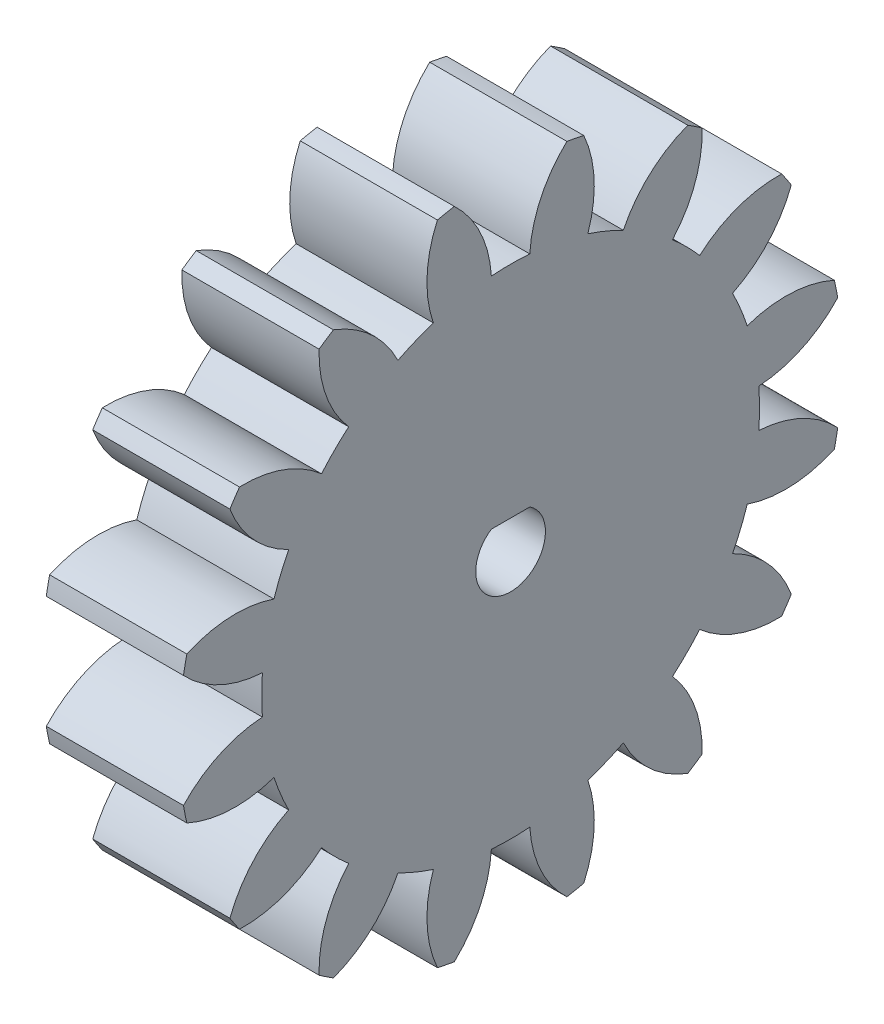
from build123d import *

# Parameters (mm, degrees)
BASPROSKE_W        = 11.811
BASPROSKE_H        = 28.575
TOOTHCUT_DEPTH     = 43.101792967
TEETHCUTS_COUNT    = 16
TEETHCUTS_ANGLE    = 337.5
BORSKE_R           = 0.396875
BORE_DEPTH         = 50.8000508
CUT_EXTRUDE1_DEPTH = 42.540449503


with BuildPart() as part:
    # BasProSke → Base-Revolve (revolve)
    with BuildSketch(Plane(origin=(0, 0, 0), x_dir=(1, 0, 0), z_dir=(0, 1, 0)), mode=Mode.PRIVATE) as base_revolve_sk:
        with Locations((5.9055, 14.2875)):
            Rectangle(BASPROSKE_W, BASPROSKE_H)
    revolve(base_revolve_sk.sketch.rotate(Axis((-10, 0, 0), (1, 0, 0)), 180), axis=Axis((-10, 0, 0), (1, 0, 0)))

    # TooCutSke → ToothCut (cut, through all)
    with BuildSketch(Plane(origin=(0, 0, 0), x_dir=(0, 0, -1), z_dir=(1, 0, 0))):
        with BuildLine():
            ThreePointArc((1.653773222, 21.366073035), (0, 21.42998), (-1.653773222, 21.366073035))
            ThreePointArc((-1.653773222, 21.366073035), (-2.605634946, 25.083646688), (-4.868483936, 28.182986789))
            ThreePointArc((-4.868483936, 28.182986789), (0, 28.6004), (4.868483936, 28.182986789))
            ThreePointArc((4.868483936, 28.182986789), (2.605634946, 25.083646688), (1.653773222, 21.366073035))
        make_face()
    toothcut = extrude(amount=TOOTHCUT_DEPTH, mode=Mode.SUBTRACT)

    # TeethCuts: ToothCut ×16 about axis
    teethcuts_axis = Axis((-10, 0, 0), (1, 0, 0))
    for i in range(1, TEETHCUTS_COUNT):
        add(toothcut.rotate(teethcuts_axis, i * TEETHCUTS_ANGLE / (TEETHCUTS_COUNT - 1)), mode=Mode.SUBTRACT)

    # BorSke → Bore (cut, symmetric)
    with BuildSketch(Plane(origin=(0, 0, 0), x_dir=(0, 0, -1), z_dir=(1, 0, 0))):
        with Locations(Location((0, 0, 0), (0, 0, 180))):
            Circle(BORSKE_R)
    extrude(amount=BORE_DEPTH, both=True, mode=Mode.SUBTRACT)

    # Sketch1 → Cut-Extrude1 (cut, through all)
    with BuildSketch(Plane(origin=(11.811, 0, 0), x_dir=(0, 0, -1), z_dir=(1, 0, 0))):
        with BuildLine():
            Line((-1.658312395, 2.5), (1.658312395, 2.5))
            ThreePointArc((1.658312395, 2.5), (0, -3), (-1.658312395, 2.5))
        make_face()
    extrude(amount=-CUT_EXTRUDE1_DEPTH, mode=Mode.SUBTRACT)


solid = part.part
